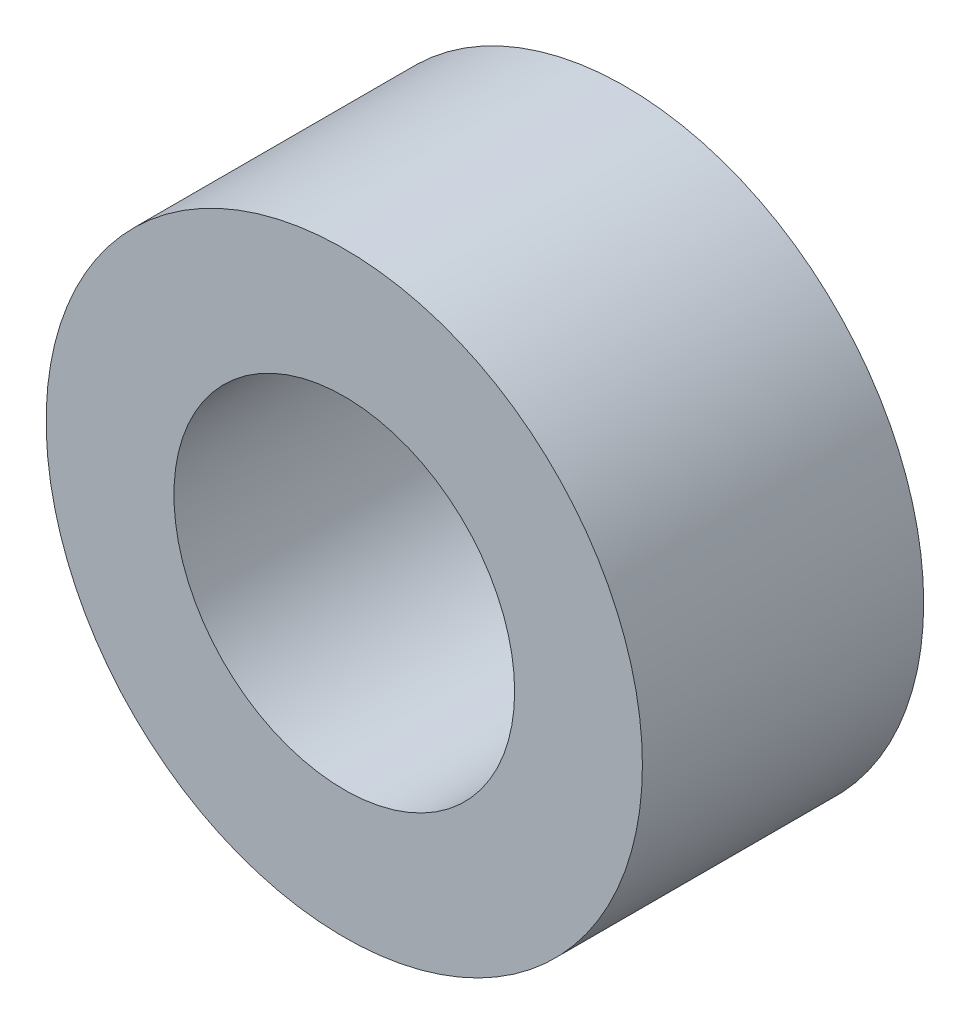
from build123d import *

# Parameters (mm, degrees)
SKETCH1_R           = 10.5
SKETCH1_R_2         = 6
BOSS_EXTRUDE1_DEPTH = 9.906


with BuildPart() as part:
    # Sketch1 → Boss-Extrude1 (new body)
    with BuildSketch(Plane.XY):
        Circle(SKETCH1_R)
        Circle(SKETCH1_R_2, mode=Mode.SUBTRACT)
    extrude(amount=BOSS_EXTRUDE1_DEPTH)


solid = part.part
